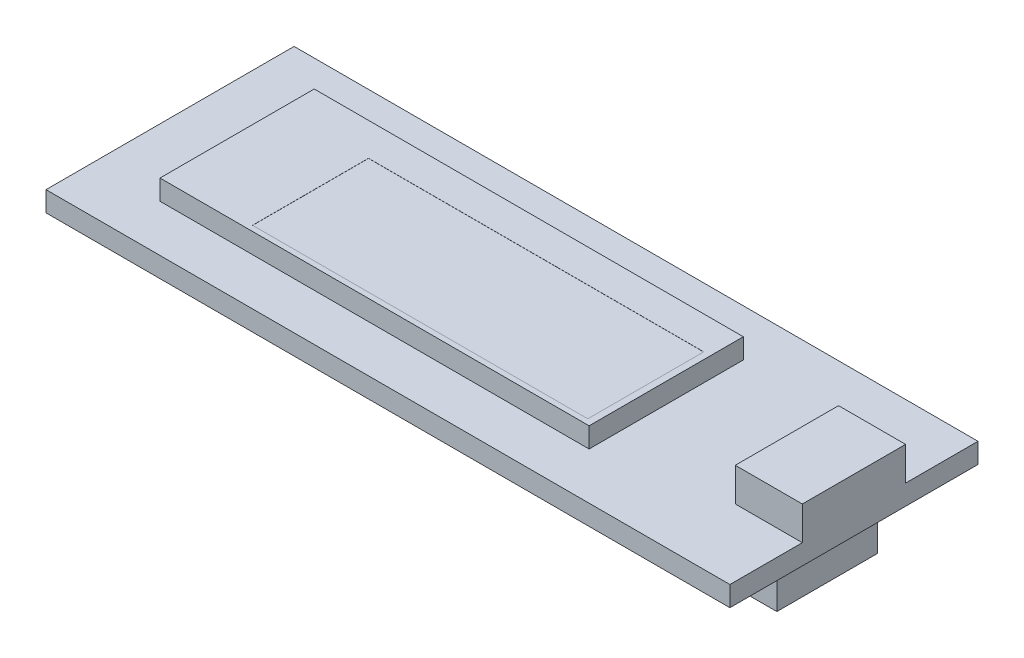
from build123d import *

# Parameters (mm, degrees)
SKETCH1_W           = 51
SKETCH1_H           = 18.5
BOSS_EXTRUDE1_DEPTH = 1.5
SKETCH2_W           = 32
SKETCH2_H           = 11.5
BOSS_EXTRUDE2_DEPTH = 1.5
SKETCH3_W           = 5
SKETCH3_H           = 7.7
BOSS_EXTRUDE3_DEPTH = 2.5
SKETCH4_W           = 4.3
SKETCH4_H           = 7.5
BOSS_EXTRUDE4_DEPTH = 4
SKETCH5_W           = 25
SKETCH5_H           = 8.65
CUT_EXTRUDE1_DEPTH  = 0.01


with BuildPart() as part:
    # Sketch1 → Boss-Extrude1 (new body)
    with BuildSketch(Plane(origin=(0, 0, 27), x_dir=(1, 0, 0), z_dir=(0, 1, 0))):
        with Locations((25.5, 27)):
            Rectangle(SKETCH1_W, SKETCH1_H)
    extrude(amount=BOSS_EXTRUDE1_DEPTH)

    # Sketch2 → Boss-Extrude2 (add)
    with BuildSketch(Plane(origin=(0, 1.5, 0), x_dir=(1, 0, 0), z_dir=(0, 1, 0))):
        with Locations((21, 0)):
            Rectangle(SKETCH2_W, SKETCH2_H)
    extrude(amount=BOSS_EXTRUDE2_DEPTH)

    # Sketch3 → Boss-Extrude3 (add)
    with BuildSketch(Plane(origin=(0, 1.5, 0), x_dir=(1, 0, 0), z_dir=(0, 1, 0))):
        with Locations((48.5, 0)):
            Rectangle(SKETCH3_W, SKETCH3_H)
    extrude(amount=BOSS_EXTRUDE3_DEPTH)

    # Sketch4 → Boss-Extrude4 (add)
    with BuildSketch(Plane.XZ):
        with Locations((46.85, 0)):
            Rectangle(SKETCH4_W, SKETCH4_H)
    extrude(amount=BOSS_EXTRUDE4_DEPTH)

    # Sketch5 → Cut-Extrude1 (cut)
    with BuildSketch(Plane(origin=(0, 3, 0), x_dir=(1, 0, 0), z_dir=(0, 1, 0))):
        with Locations((24, -1.025)):
            Rectangle(SKETCH5_W, SKETCH5_H)
    extrude(amount=-CUT_EXTRUDE1_DEPTH, mode=Mode.SUBTRACT)


solid = part.part
